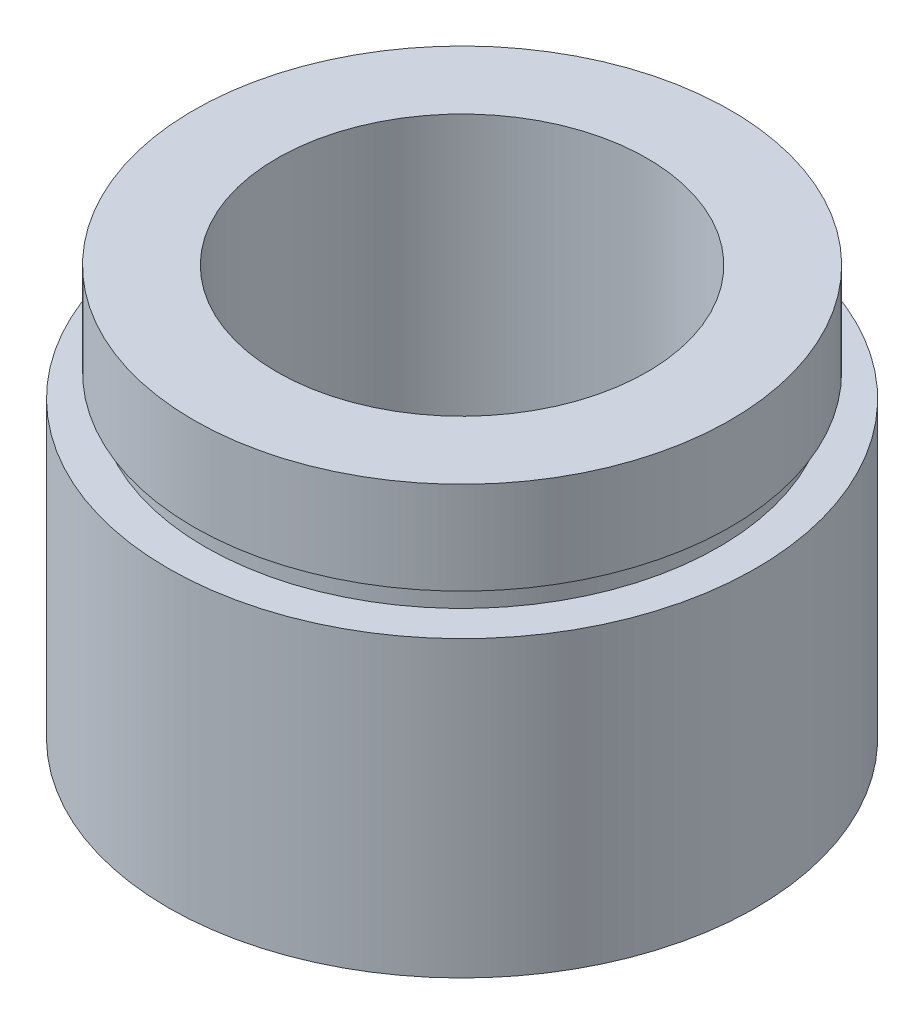
from build123d import *


with BuildPart() as part:
    # 草图1 → 旋转1 (revolve)
    with BuildSketch(Plane.XY, mode=Mode.PRIVATE) as revolve_1_sk:
        Polygon((11.1, 0), (11.1, 4.5), (11.7, 4.5), (11.7, 5.5), (8, 5.5), (8, 17.7), (11.6, 17.7), (11.6, 13.7), (11.1, 13.7), (11.1, 12.7), (12.7, 12.7), (12.7, 0), align=None)
    revolve(revolve_1_sk.sketch.rotate(Axis((0, 161.376166943, 0), (0, -1, 0)), 90), axis=Axis((0, 161.376166943, 0), (0, -1, 0)))  # turned: the seam where the file's is


solid = part.part
